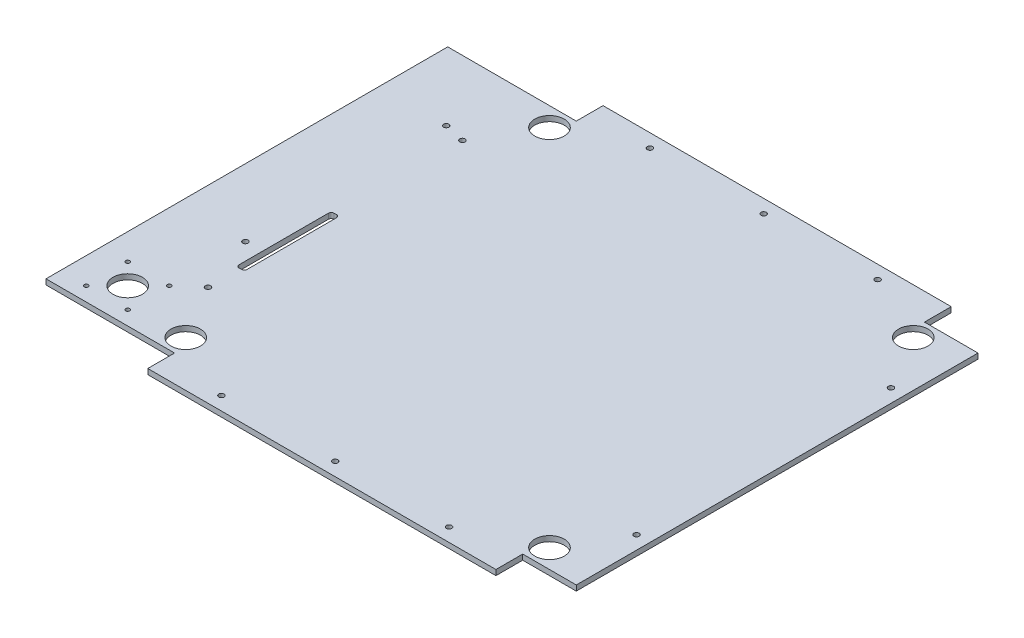
from build123d import *

# Parameters (mm, degrees)
SKETCH1_4_R         = 11
SKETCH1_4_R_2       = 2
SKETCH1_4_R_3       = 1.5
BOSS_EXTRUDE3_DEPTH = 4


with BuildPart() as part:
    # Sketch1_4 → Boss-Extrude3 (new body)
    with BuildSketch(Plane(origin=(0, 0, 0), x_dir=(1, 0, 0), z_dir=(0, 1, 0))):
        Polygon((130, -150), (170, -150), (170, 150), (130, 150), (130, 170), (-130, 170), (-130, 150), (-226, 150), (-226, -150), (-130, -150), (-130, -170), (130, -170), align=None)
        with Locations((135.829506597, -135.829506597)):
            Circle(SKETCH1_4_R, mode=Mode.SUBTRACT)
        with Locations((160, -95)):
            Circle(SKETCH1_4_R_2, mode=Mode.SUBTRACT)
        with Locations((160, 95)):
            Circle(SKETCH1_4_R_2, mode=Mode.SUBTRACT)
        with Locations((135.829506597, 135.829506597)):
            Circle(SKETCH1_4_R, mode=Mode.SUBTRACT)
        with Locations((85, -160)):
            Circle(SKETCH1_4_R_2, mode=Mode.SUBTRACT)
        with Locations((-85, -160)):
            Circle(SKETCH1_4_R_2, mode=Mode.SUBTRACT)
        with Locations((0, -160)):
            Circle(SKETCH1_4_R_2, mode=Mode.SUBTRACT)
        with BuildLine():
            ThreePointArc((-163, -2), (-162.414213562, -0.585786438), (-161, 0))
            Line((-161, 0), (-159, 0))
            ThreePointArc((-159, 0), (-157.585786438, -0.585786438), (-157, -2))
            Line((-157, -2), (-157, -68.911348687))
            ThreePointArc((-157, -68.911348687), (-157.585786438, -70.325562249), (-159, -70.911348687))
            Line((-159, -70.911348687), (-161, -70.911348687))
            ThreePointArc((-161, -70.911348687), (-162.414213562, -70.325562249), (-163, -68.911348687))
            Line((-163, -68.911348687), (-163, -2))
        make_face(mode=Mode.SUBTRACT)
        with Locations((-160, 95)):
            Circle(SKETCH1_4_R_2, mode=Mode.SUBTRACT)
        with Locations((-135.829506597, 135.829506597)):
            Circle(SKETCH1_4_R, mode=Mode.SUBTRACT)
        with Locations((-135.829506597, -135.829506597)):
            Circle(SKETCH1_4_R, mode=Mode.SUBTRACT)
        with Locations((-160, -95)):
            Circle(SKETCH1_4_R_2, mode=Mode.SUBTRACT)
        with Locations((85, 160)):
            Circle(SKETCH1_4_R_2, mode=Mode.SUBTRACT)
        with Locations((0, 160)):
            Circle(SKETCH1_4_R_2, mode=Mode.SUBTRACT)
        with Locations((-85, 160)):
            Circle(SKETCH1_4_R_2, mode=Mode.SUBTRACT)
        with Locations((-206.5, -139.5)):
            Circle(SKETCH1_4_R_3, mode=Mode.SUBTRACT)
        with Locations((-175.5, -139.5)):
            Circle(SKETCH1_4_R_3, mode=Mode.SUBTRACT)
        with Locations((-206.5, -108.5)):
            Circle(SKETCH1_4_R_3, mode=Mode.SUBTRACT)
        with Locations((-191, -124)):
            Circle(SKETCH1_4_R, mode=Mode.SUBTRACT)
        with Locations((-175.5, -108.5)):
            Circle(SKETCH1_4_R_3, mode=Mode.SUBTRACT)
        with Locations((-175.6, -51.5)):
            Circle(SKETCH1_4_R_2, mode=Mode.SUBTRACT)
        with Locations((-175.6, 98.5)):
            Circle(SKETCH1_4_R_2, mode=Mode.SUBTRACT)
    extrude(amount=BOSS_EXTRUDE3_DEPTH)


solid = part.part
